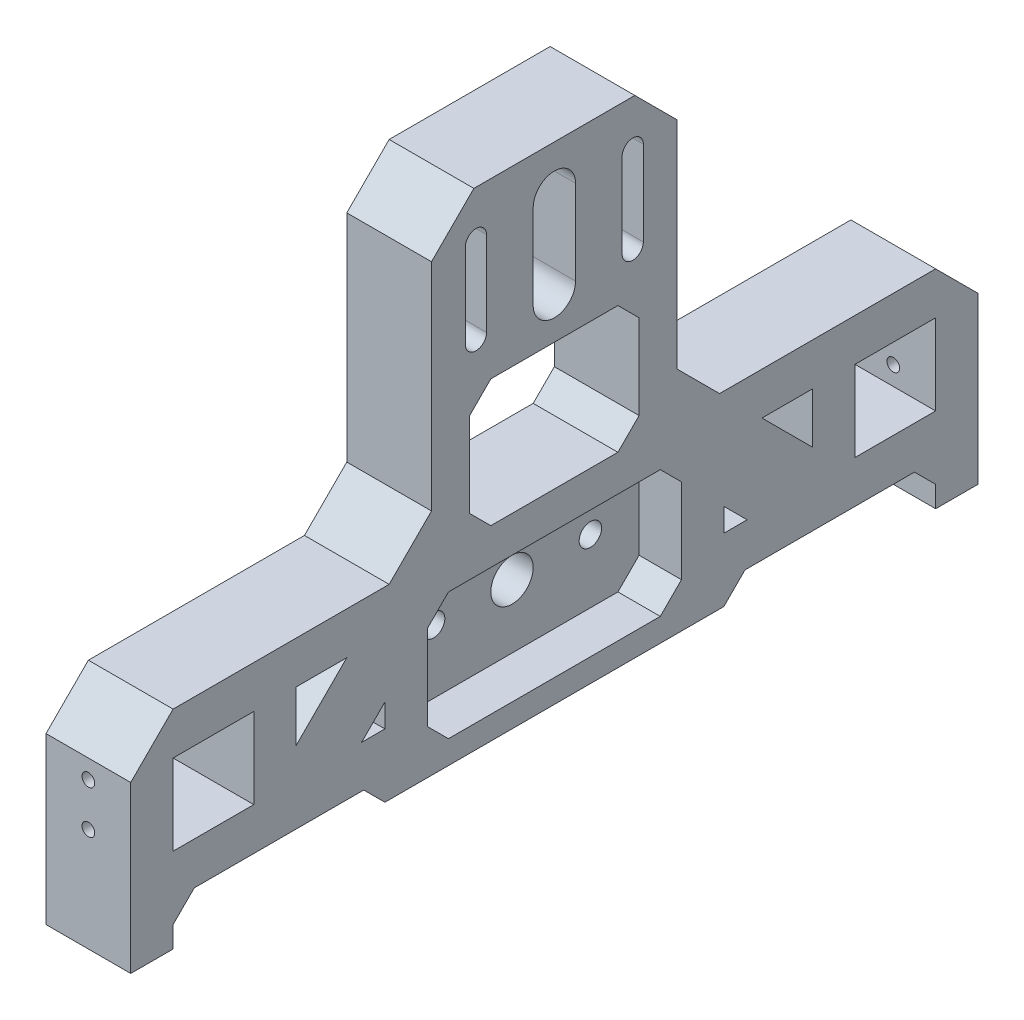
from build123d import *

# Parameters (mm, degrees)
SKETCH1_W           = 100
SKETCH1_H           = 120
BOSS_EXTRUDE1_DEPTH = 20
SKETCH2_W           = 19.05
SKETCH2_H           = 19.05
CUT_EXTRUDE1_DEPTH  = 20
SKETCH3_R           = 1.5
CUT_EXTRUDE2_DEPTH  = 20
SKETCH5_R           = 5
SKETCH5_R_2         = 2.65
CUT_EXTRUDE3_DEPTH  = 21
SKETCH6_W           = 60
SKETCH6_H           = 30
CUT_EXTRUDE4_DEPTH  = 10
CUT_EXTRUDE5_DEPTH  = 21
SKETCH8_W           = 71
SKETCH8_H           = 70.95
CUT_EXTRUDE6_DEPTH  = 21
CHAMFER1_SIZE       = 10
SKETCH9_W           = 50
SKETCH9_H           = 10
SKETCH9_W_2         = 40
SKETCH9_H_2         = 30
CUT_EXTRUDE7_DEPTH  = 21
CHAMFER2_SIZE       = 5
CUT_EXTRUDE8_DEPTH  = 21
SKETCH12_W          = 80
SKETCH12_H          = 5
CUT_EXTRUDE9_DEPTH  = 21


with BuildPart() as part:
    # Sketch1 → Boss-Extrude1 (new body)
    with BuildSketch(Plane(origin=(0, 0, 0), x_dir=(0, 0, -1), z_dir=(1, 0, 0))):
        with Locations((-50, 60)):
            Rectangle(SKETCH1_W, SKETCH1_H)
    boss_extrude1 = extrude(amount=BOSS_EXTRUDE1_DEPTH)

    # Sketch2 → Cut-Extrude1 (cut)
    with BuildSketch(Plane(origin=(20, 0, 0), x_dir=(0, 0, -1), z_dir=(1, 0, 0))):
        with Locations((-80.475, 29.525)):
            Rectangle(SKETCH2_W, SKETCH2_H)
    cut_extrude1 = extrude(amount=-CUT_EXTRUDE1_DEPTH, mode=Mode.SUBTRACT)

    # Sketch3 → Cut-Extrude2 (cut)
    with BuildSketch(Plane.XY.offset(100)):
        with Locations((10, 34.605)):
            Circle(SKETCH3_R)
        with Locations((10, 24.445)):
            Circle(SKETCH3_R)
    cut_extrude2 = extrude(amount=-CUT_EXTRUDE2_DEPTH, mode=Mode.SUBTRACT)

    # Mirror1: Boss-Extrude1, Cut-Extrude1, Cut-Extrude2 across plane
    add(boss_extrude1.mirror(Plane(origin=(20, 0, 0), x_dir=(1, 0, 0), z_dir=(0, 0, 1))))
    add(cut_extrude1.mirror(Plane(origin=(20, 0, 0), x_dir=(1, 0, 0), z_dir=(0, 0, 1))), mode=Mode.SUBTRACT)
    add(cut_extrude2.mirror(Plane(origin=(20, 0, 0), x_dir=(1, 0, 0), z_dir=(0, 0, 1))), mode=Mode.SUBTRACT)

    # Sketch5 → Cut-Extrude3 (cut, through all)
    with BuildSketch(Plane(origin=(20, 0, 0), x_dir=(0, 0, -1), z_dir=(1, 0, 0))):
        with Locations((0, 25.5)):
            Circle(SKETCH5_R)
        with Locations((-18.5, 25.5)):
            Circle(SKETCH5_R_2)
        with Locations((18.5, 25.5)):
            Circle(SKETCH5_R_2)
    extrude(amount=-CUT_EXTRUDE3_DEPTH, mode=Mode.SUBTRACT)

    # Sketch6 → Cut-Extrude4 (cut)
    with BuildSketch(Plane(origin=(20, 0, 0), x_dir=(0, 0, -1), z_dir=(1, 0, 0))):
        with Locations((0, 25.5)):
            Rectangle(SKETCH6_W, SKETCH6_H)
    extrude(amount=-CUT_EXTRUDE4_DEPTH, mode=Mode.SUBTRACT)

    # Sketch7 → Cut-Extrude5 (cut, through all)
    with BuildSketch(Plane(origin=(20, 0, 0), x_dir=(0, 0, -1), z_dir=(1, 0, 0))):
        with BuildLine():
            Line((5, 109.05), (5, 89.05))
            ThreePointArc((5, 89.05), (0, 84.05), (-5, 89.05))
            Line((-5, 89.05), (-5, 109.05))
            ThreePointArc((-5, 109.05), (0, 114.05), (5, 109.05))
        make_face()
        with BuildLine():
            Line((-16, 109.05), (-16, 89.05))
            ThreePointArc((-16, 89.05), (-18.5, 86.55), (-21, 89.05))
            Line((-21, 89.05), (-21, 109.05))
            ThreePointArc((-21, 109.05), (-18.5, 111.55), (-16, 109.05))
        make_face()
        with BuildLine():
            Line((16, 109.05), (16, 89.05))
            ThreePointArc((16, 89.05), (18.5, 86.55), (21, 89.05))
            Line((21, 89.05), (21, 109.05))
            ThreePointArc((21, 109.05), (18.5, 111.55), (16, 109.05))
        make_face()
    extrude(amount=-CUT_EXTRUDE5_DEPTH, mode=Mode.SUBTRACT)

    # Sketch8 → Cut-Extrude6 (cut, through all)
    with BuildSketch(Plane(origin=(20, 0, 0), x_dir=(0, 0, -1), z_dir=(1, 0, 0))):
        with Locations((-64.5, 84.525)):
            Rectangle(SKETCH8_W, SKETCH8_H)
        with Locations((64.5, 84.525)):
            Rectangle(SKETCH8_W, SKETCH8_H)
    extrude(amount=-CUT_EXTRUDE6_DEPTH, mode=Mode.SUBTRACT)

    # Chamfer1
    chamfer1_edges = [part.edges().sort_by_distance(p)[0] for p in [
        (10, 49.05, 100),
        (10, 120, 29),
        (10, 49.05, 29),
        (10, 120, -29),
        (10, 49.05, -100),
        (10, 49.05, -29),
    ]]
    chamfer(chamfer1_edges, length=CHAMFER1_SIZE)

    # Sketch9 → Cut-Extrude7 (cut, through all)
    with BuildSketch(Plane(origin=(20, 0, 0), x_dir=(0, 0, -1), z_dir=(1, 0, 0))):
        with Locations((-65, 5)):
            Rectangle(SKETCH9_W, SKETCH9_H)
        with Locations((65, 5)):
            Rectangle(SKETCH9_W, SKETCH9_H)
        with Locations((0, 64.05)):
            Rectangle(SKETCH9_W_2, SKETCH9_H_2)
    extrude(amount=-CUT_EXTRUDE7_DEPTH, mode=Mode.SUBTRACT)

    # Chamfer2
    chamfer2_edges = [part.edges().sort_by_distance(p)[0] for p in [
        (10, 10, 90),
        (10, 10, 40),
        (10, 10, -40),
        (10, 10, -90),
        (10, 49.05, 20),
        (10, 79.05, 20),
        (10, 79.05, -20),
        (10, 49.05, -20),
        (15, 10.5, 30),
        (15, 40.5, 30),
        (15, 40.5, -30),
        (15, 10.5, -30),
    ]]
    chamfer(chamfer2_edges, length=CHAMFER2_SIZE)

    # Sketch11 → Cut-Extrude8 (cut, through all)
    with BuildSketch(Plane(origin=(20, 0, 0), x_dir=(0, 0, -1), z_dir=(1, 0, 0))):
        Polygon((-40, 25.5), (-45.5, 20), (-40, 20), align=None)
        Polygon((-49, 39.05), (-60.95, 27.1), (-60.95, 39.05), align=None)
    cut_extrude8 = extrude(amount=-CUT_EXTRUDE8_DEPTH, mode=Mode.SUBTRACT)

    # Mirror2: Cut-Extrude8 across plane
    add(cut_extrude8.mirror(Plane.XY), mode=Mode.SUBTRACT)

    # Sketch12 → Cut-Extrude9 (cut, through all)
    with BuildSketch(Plane.ZY):
        with Locations((0, 2.5)):
            Rectangle(SKETCH12_W, SKETCH12_H)
    extrude(amount=-CUT_EXTRUDE9_DEPTH, mode=Mode.SUBTRACT)


solid = part.part
